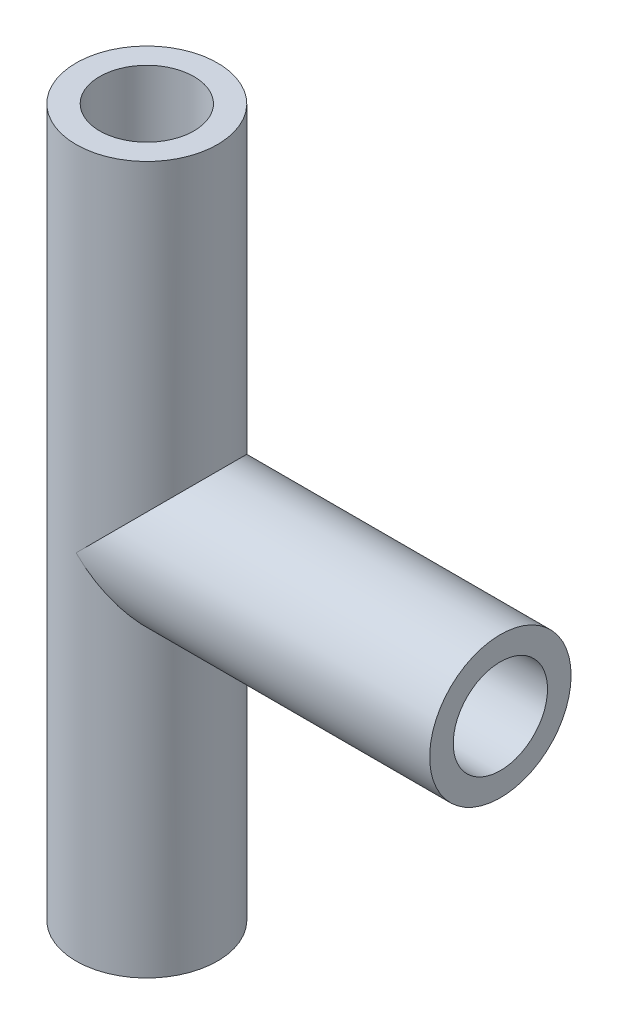
from build123d import *

# Parameters (mm, degrees)
BOSS_EXTRUDE2_DEPTH      = 15
BOSS_EXTRUDE2_DEPTH_BACK = 15
SKETCH4_R                = 3
SKETCH5_R                = 3
BOSS_EXTRUDE3_DEPTH      = 15
SKETCH6_R                = 2
CUT_EXTRUDE1_DEPTH       = 34.674916481
SKETCH7_R                = 2
CUT_EXTRUDE2_DEPTH       = 15


with BuildPart() as part:
    # Sketch4 → Boss-Extrude2 (new, two sides: drawn at the far end of the back side and taken through both)
    with BuildSketch(Plane(origin=(0, 0, 0), x_dir=(1, 0, 0), z_dir=(0, 1, 0)).offset(-BOSS_EXTRUDE2_DEPTH_BACK)):
        Circle(SKETCH4_R)
    extrude(amount=BOSS_EXTRUDE2_DEPTH + BOSS_EXTRUDE2_DEPTH_BACK)

    # Sketch5 → Boss-Extrude3 (add)
    with BuildSketch(Plane(origin=(0, 0, 0), x_dir=(0, 0, -1), z_dir=(1, 0, 0))):
        Circle(SKETCH5_R)
    extrude(amount=BOSS_EXTRUDE3_DEPTH)

    # Sketch6 → Cut-Extrude1 (cut, through all)
    with BuildSketch(Plane.XZ.offset(15)):
        Circle(SKETCH6_R)
    extrude(amount=-CUT_EXTRUDE1_DEPTH, mode=Mode.SUBTRACT)

    # Sketch7 → Cut-Extrude2 (cut)
    with BuildSketch(Plane(origin=(15, 0, 0), x_dir=(0, 0, -1), z_dir=(1, 0, 0))):
        Circle(SKETCH7_R)
    extrude(amount=-CUT_EXTRUDE2_DEPTH, mode=Mode.SUBTRACT)


solid = part.part
